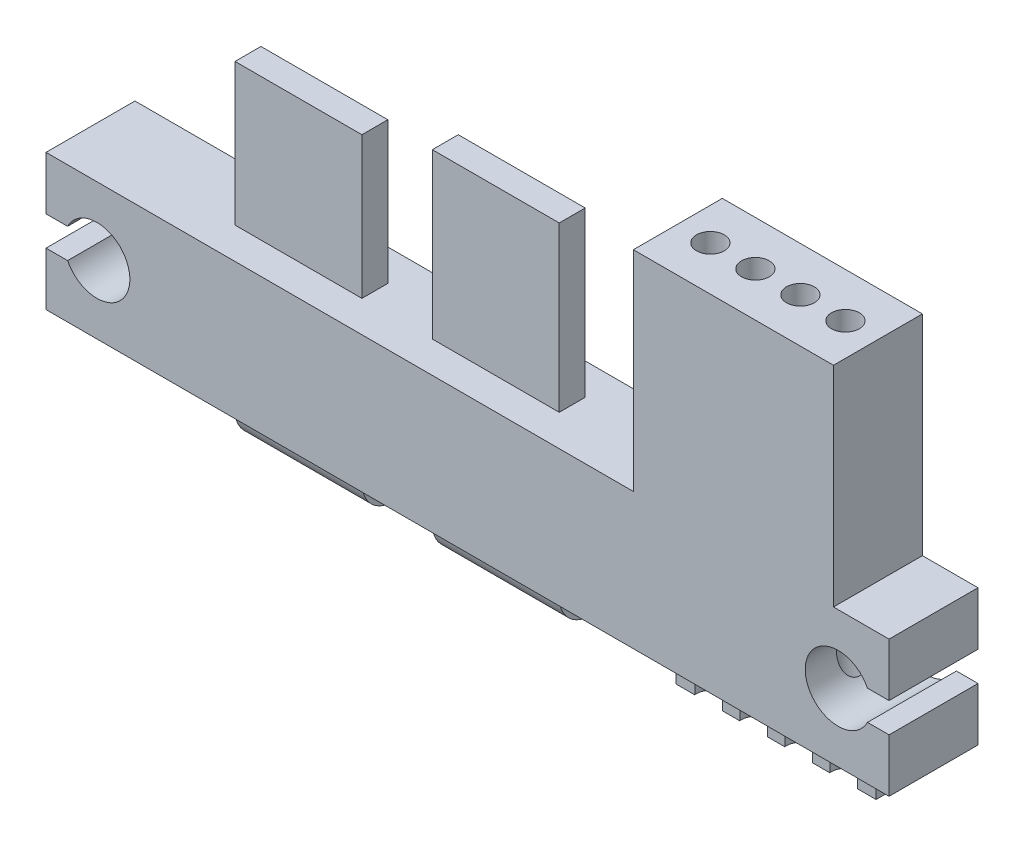
from build123d import *

# Parameters (mm, degrees)
EXTRUDE_1_DEPTH     = 2.4
SKETCH_2_W          = 6.85
SKETCH_2_H          = 1.4
EXTRUDE_2_DEPTH     = 7.65
SKETCH_3_W          = 6.85
SKETCH_3_H          = 1.4
EXTRUDE_3_DEPTH     = 1.2
SKETCH_5_W          = 6.85
SKETCH_5_H          = 1.4
SKETCH_6_W          = 1.2
SKETCH_6_H          = 2.5
EXTRUDE_4_DEPTH     = 2.8
CUT_EXTRUDE_1_DEPTH = 8.4
SKETCH_8_R          = 0.75
CUT_EXTRUDE_2_DEPTH = 22.65


with BuildPart() as part:
    # 草图1 → 凸台-拉伸1 (new body, symmetric)
    with BuildSketch(Plane.XY):
        Polygon((-22.75, 7.35), (-22.75, 0), (22.75, 0), (22.75, 7.35), (19.75, 7.35), (19.75, 18.65), (8.95, 18.65), (8.95, 7.35), align=None)
    extrude(amount=EXTRUDE_1_DEPTH, both=True)

    # 草图2 → 凸台-拉伸2 (add)
    with BuildSketch(Plane(origin=(0, 7.35, 0), x_dir=(1, 0, 0), z_dir=(0, 1, 0))):
        with Locations((-10.825, 0)):
            Rectangle(SKETCH_2_W, SKETCH_2_H)
        with Locations((-0.175, 0)):
            Rectangle(SKETCH_2_W, SKETCH_2_H)
    extrude(amount=EXTRUDE_2_DEPTH)

    # 草图3 → 凸台-拉伸3 (add)
    with BuildSketch(Plane(origin=(0, 15, 0), x_dir=(1, 0, 0), z_dir=(0, 1, 0))):
        with Locations((-0.175, 0)):
            Rectangle(SKETCH_3_W, SKETCH_3_H)
    extrude(amount=EXTRUDE_3_DEPTH)

    # 扫描1: sweep along a path in 草图4
    with BuildLine(Plane(origin=(0, 0, 0), x_dir=(0, 0, -1), z_dir=(1, 0, 0))) as sweep_1_path:
        Line((0, 0), (0, -1.3))
        ThreePointArc((0, -1.3), (0.292893219, -2.007106781), (1, -2.3))
        Line((1, -2.3), (5, -2.3))
    # 草图5 → 扫描1 (sweep)
    with BuildSketch(Plane.XZ):
        with Locations((-0.175, 0)):
            Rectangle(SKETCH_5_W, SKETCH_5_H)
        with Locations((-10.825, 0)):
            Rectangle(SKETCH_5_W, SKETCH_5_H)
    sweep(path=sweep_1_path.line)

    # 草图6 → 凸台-拉伸4 (add)
    with BuildSketch(Plane.XZ):
        with Locations((16.75, -1.15)):
            Rectangle(SKETCH_6_W, SKETCH_6_H)
        with Locations((19.15, -1.15)):
            Rectangle(SKETCH_6_W, SKETCH_6_H)
        with Locations((14.35, -1.15)):
            Rectangle(SKETCH_6_W, SKETCH_6_H)
        with Locations((11.95, -1.15)):
            Rectangle(SKETCH_6_W, SKETCH_6_H)
        with Locations((9.55, -1.15)):
            Rectangle(SKETCH_6_W, SKETCH_6_H)
    extrude(amount=EXTRUDE_4_DEPTH)

    # 草图7 → 切除-拉伸1 (cut, through all)
    with BuildSketch(Plane.XY.offset(2.4)):
        with BuildLine():
            Line((-21.584495188, 4.475), (-22.75, 4.475))
            Line((-22.75, 4.475), (-22.75, 2.875))
            Line((-22.75, 2.875), (-21.584495188, 2.875))
            ThreePointArc((-21.584495188, 2.875), (-18.225, 3.675), (-21.584495188, 4.475))
        make_face()
        with BuildLine():
            Line((22.75, 2.875), (22.75, 4.475))
            Line((22.75, 4.475), (21.584495188, 4.475))
            ThreePointArc((21.584495188, 4.475), (18.225, 3.675), (21.584495188, 2.875))
            Line((21.584495188, 2.875), (22.75, 2.875))
        make_face()
    extrude(amount=-CUT_EXTRUDE_1_DEPTH, mode=Mode.SUBTRACT)

    # 草图8 → 切除-拉伸2 (cut, through all)
    with BuildSketch(Plane(origin=(0, 18.65, 0), x_dir=(1, 0, 0), z_dir=(0, 1, 0))):
        with Locations((10.706638524, 0)):
            Circle(SKETCH_8_R)
        with Locations((13.135546175, 0)):
            Circle(SKETCH_8_R)
        with Locations((15.564453825, 0)):
            Circle(SKETCH_8_R)
        with Locations((17.993361476, 0)):
            Circle(SKETCH_8_R)
    extrude(amount=-CUT_EXTRUDE_2_DEPTH, mode=Mode.SUBTRACT)


solid = part.part
